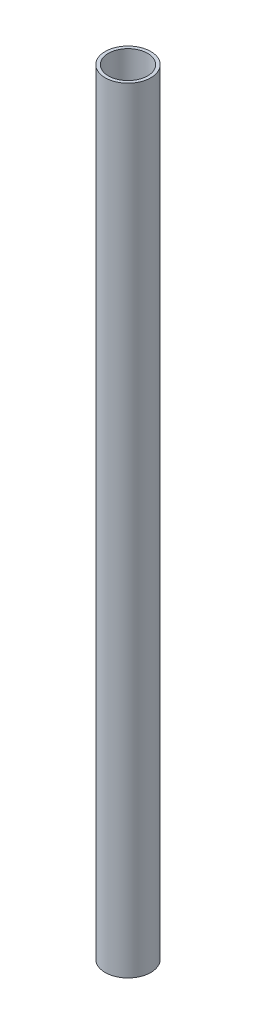
from build123d import *

# Parameters (mm, degrees)
SKETCH1_R           = 12.7
BOSS_EXTRUDE1_DEPTH = 431.8
SKETCH2_R           = 10.922
CUT_EXTRUDE1_DEPTH  = 432.8


with BuildPart() as part:
    # Sketch1 → Boss-Extrude1 (new body)
    with BuildSketch(Plane(origin=(0, 0, 0), x_dir=(1, 0, 0), z_dir=(0, 1, 0))):
        Circle(SKETCH1_R)
    extrude(amount=BOSS_EXTRUDE1_DEPTH)

    # Sketch2 → Cut-Extrude1 (cut, through all)
    with BuildSketch(Plane.XZ):
        Circle(SKETCH2_R)
    extrude(amount=-CUT_EXTRUDE1_DEPTH, mode=Mode.SUBTRACT)


solid = part.part
